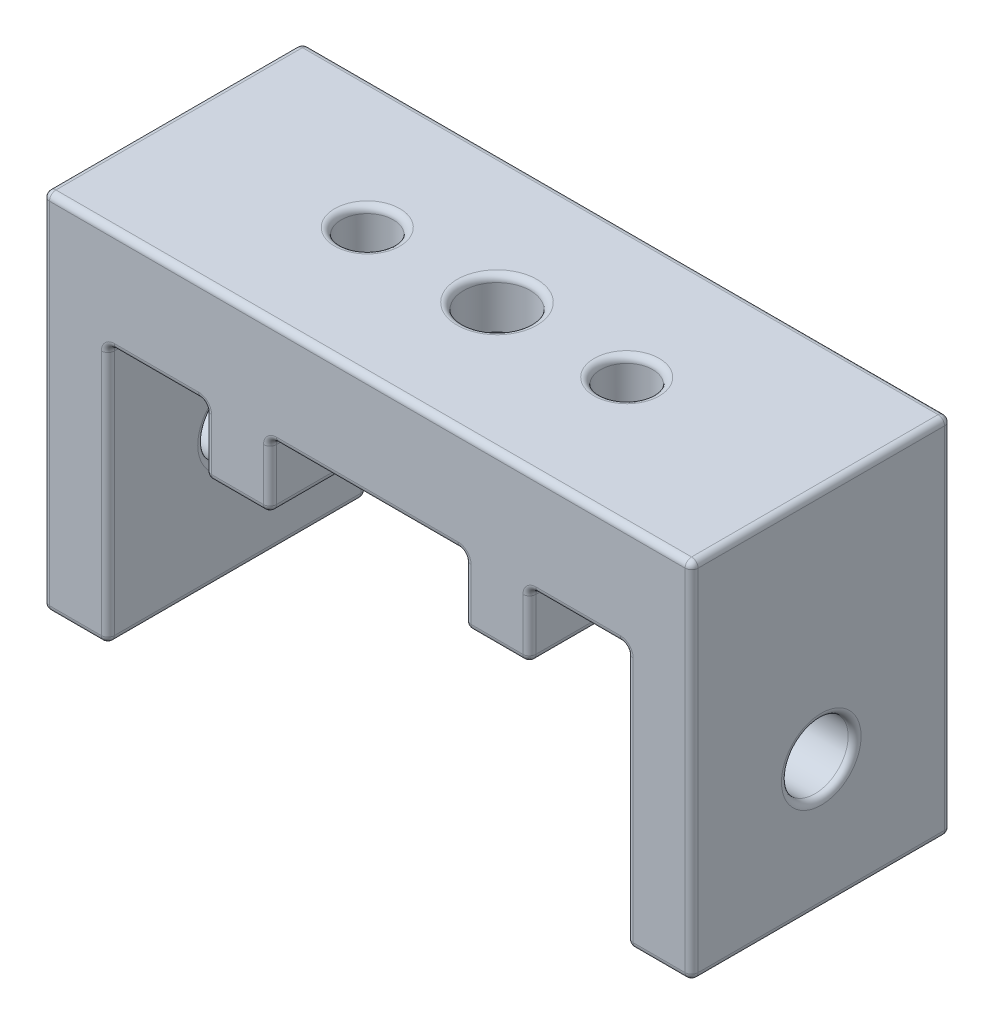
from build123d import *

# Parameters (mm, degrees)
BOSS_EXTRUDE1_DEPTH              = 25.4
SKETCH2_W                        = 6.35
SKETCH2_H                        = 7.62
BOSS_EXTRUDE2_DEPTH              = 6.35
F_1_4_20_TAPPED_HOLE1_D          = 5.1054
F_97_0_0059_DIAMETER_HOLE1_D     = 6.5278
F_97_0_0059_DIAMETER_HOLE1_DEPTH = 6.35
F_97_0_0059_DIAMETER_HOLE2_D     = 6.5278
MIRROR3_COPY_1_SKETCH_W          = 6.35
MIRROR3_COPY_1_SKETCH_H          = 7.62
MIRROR3_COPY_1_DEPTH             = 6.35
F_97_0_0059_DIAMETER_HOLE3_D     = 6.5278
FILLET2_R                        = 0.635
BOSS_EXTRUDE3_DEPTH              = 5.334


with BuildPart() as part:
    # Sketch1 → Boss-Extrude1 (new body)
    with BuildSketch(Plane.XY):
        Polygon((0, 0), (6.35, 0), (6.35, 25.4), (57.15, 25.4), (57.15, 0), (63.5, 0), (63.5, 35.56), (0, 35.56), align=None)
    extrude(amount=BOSS_EXTRUDE1_DEPTH)

    # Sketch2 → Boss-Extrude2 (add)
    with BuildSketch(Plane.XZ.offset(-25.4)):
        with Locations((19.05, 3.81)):
            Rectangle(SKETCH2_W, SKETCH2_H)
    boss_extrude2 = extrude(amount=BOSS_EXTRUDE2_DEPTH)

    # Mirror1: Boss-Extrude2 across plane
    add(boss_extrude2.mirror(Plane.XY.offset(12.7)))

    # 1/4-20 Tapped Hole1 (through all)
    with Locations(Plane(origin=(0, 35.56, 0), x_dir=(-1, 0, 0), z_dir=(0, 1, 0))):
        with Locations((-19.05, 12.7)):
            f_1_4_20_tapped_hole1 = Hole(F_1_4_20_TAPPED_HOLE1_D / 2)

    # #97 (0.0059) Diameter Hole1
    with Locations(Plane(origin=(6.35, 0, 0), x_dir=(0, 0, -1), z_dir=(1, 0, 0))):
        with Locations((-12.7, 12.7)):
            Hole(F_97_0_0059_DIAMETER_HOLE1_D / 2, depth=F_97_0_0059_DIAMETER_HOLE1_DEPTH)

    # #97 (0.0059) Diameter Hole2 (through all)
    with Locations(Plane.ZY.offset(-57.15)):
        with Locations((12.7, 12.7)):
            Hole(F_97_0_0059_DIAMETER_HOLE2_D / 2)

    # Mirror2: 1/4-20 Tapped Hole1 across plane
    add(f_1_4_20_tapped_hole1.mirror(Plane(origin=(31.75, 0, 0), x_dir=(0, 0, 1), z_dir=(1, 0, 0))), mode=Mode.SUBTRACT)

    # Mirror3: Boss-Extrude2 across plane
    add(boss_extrude2.mirror(Plane(origin=(31.75, 0, 0), x_dir=(0, 0, 1), z_dir=(1, 0, 0))))

    # Mirror3 copy 1 sketch → Mirror3 copy 1 (add)
    with BuildSketch(Plane(origin=(63.5, 25.4, 25.4), x_dir=(-1, 0, 0), z_dir=(0, -1, 0))):
        with Locations((19.05, 3.81)):
            Rectangle(MIRROR3_COPY_1_SKETCH_W, MIRROR3_COPY_1_SKETCH_H)
    extrude(amount=MIRROR3_COPY_1_DEPTH)

    # #97 (0.0059) Diameter Hole3 (through all)
    with Locations(Plane.XZ.offset(-25.4)):
        with Locations((31.75, 12.7)):
            Hole(F_97_0_0059_DIAMETER_HOLE3_D / 2)

    # Fillet2
    fillet2_edges = [part.edges().sort_by_distance(p)[0] for p in [
        (6.35, 12.7, 25.4),
        (3.175, 0, 0),
        (0, 17.78, 0),
        (11.1125, 25.4, 25.4),
        (0, 35.56, 12.7),
        (63.5, 35.56, 12.7),
        (63.5, 0, 12.7),
        (57.15, 0, 12.7),
        (57.15, 25.4, 12.7),
        (6.35, 25.4, 12.7),
        (6.35, 0, 12.7),
        (0, 0, 12.7),
        (57.15, 12.7, 25.4),
        (60.325, 0, 25.4),
        (63.5, 17.78, 25.4),
        (31.75, 25.4, 0),
        (31.75, 35.56, 25.4),
        (15.875, 25.4, 3.81),
        (15.875, 22.225, 7.62),
        (15.875, 22.225, 0),
        (22.225, 25.4, 3.81),
        (22.225, 22.225, 0),
        (19.05, 25.4, 7.62),
        (22.225, 22.225, 7.62),
        (15.875, 19.05, 3.81),
        (19.05, 19.05, 0),
        (22.225, 19.05, 3.81),
        (19.05, 19.05, 7.62),
        (31.75, 25.4, 25.4),
        (15.875, 19.05, 21.59),
        (15.875, 22.225, 25.4),
        (19.05, 19.05, 17.78),
        (15.875, 22.225, 17.78),
        (22.225, 19.05, 21.59),
        (22.225, 22.225, 17.78),
        (19.05, 19.05, 25.4),
        (22.225, 22.225, 25.4),
        (15.875, 25.4, 21.59),
        (0, 17.78, 25.4),
        (22.225, 25.4, 21.59),
        (19.05, 25.4, 17.78),
        (16.4973, 35.56, 12.7),
        (6.35, 12.7, 9.4361),
        (0, 12.7, 9.4361),
        (57.15, 12.7, 15.9639),
        (63.5, 12.7, 15.9639),
        (47.0027, 25.4, 12.7),
        (47.0027, 35.56, 12.7),
        (52.3875, 25.4, 0),
        (3.175, 0, 25.4),
        (47.625, 19.05, 3.81),
        (47.625, 22.225, 0),
        (44.45, 19.05, 7.62),
        (47.625, 22.225, 7.62),
        (41.275, 19.05, 3.81),
        (41.275, 22.225, 7.62),
        (44.45, 19.05, 0),
        (41.275, 22.225, 0),
        (47.625, 25.4, 3.81),
        (41.275, 25.4, 3.81),
        (44.45, 25.4, 7.62),
        (31.75, 35.56, 0),
        (52.3875, 25.4, 25.4),
        (63.5, 17.78, 0),
        (47.625, 25.4, 21.59),
        (47.625, 22.225, 17.78),
        (47.625, 22.225, 25.4),
        (41.275, 25.4, 21.59),
        (41.275, 22.225, 25.4),
        (44.45, 25.4, 17.78),
        (41.275, 22.225, 17.78),
        (47.625, 19.05, 21.59),
        (44.45, 19.05, 25.4),
        (41.275, 19.05, 21.59),
        (44.45, 19.05, 17.78),
        (60.325, 0, 0),
        (57.15, 12.7, 0),
        (11.1125, 25.4, 0),
        (6.35, 12.7, 0),
        (35.0139, 25.4, 12.7),
        (35.0139, 35.56, 12.7),
    ]]
    fillet(fillet2_edges, radius=FILLET2_R)


with BuildPart() as body_2:
    # Sketch13 → Boss-Extrude3 (new body)
    with BuildSketch(Plane.XZ.offset(-25.4)):
        Polygon((31.75, 19.00581964), (26.289, 15.85290982), (26.289, 9.54709018), (31.75, 6.39418036), (37.211, 9.54709018), (37.211, 15.85290982), align=None)
    extrude(amount=-BOSS_EXTRUDE3_DEPTH)


with BuildPart() as part_1:
    add(part.part)

    # Combine1: cut body 2
    add(body_2.part, mode=Mode.SUBTRACT)


solid = part_1.part
